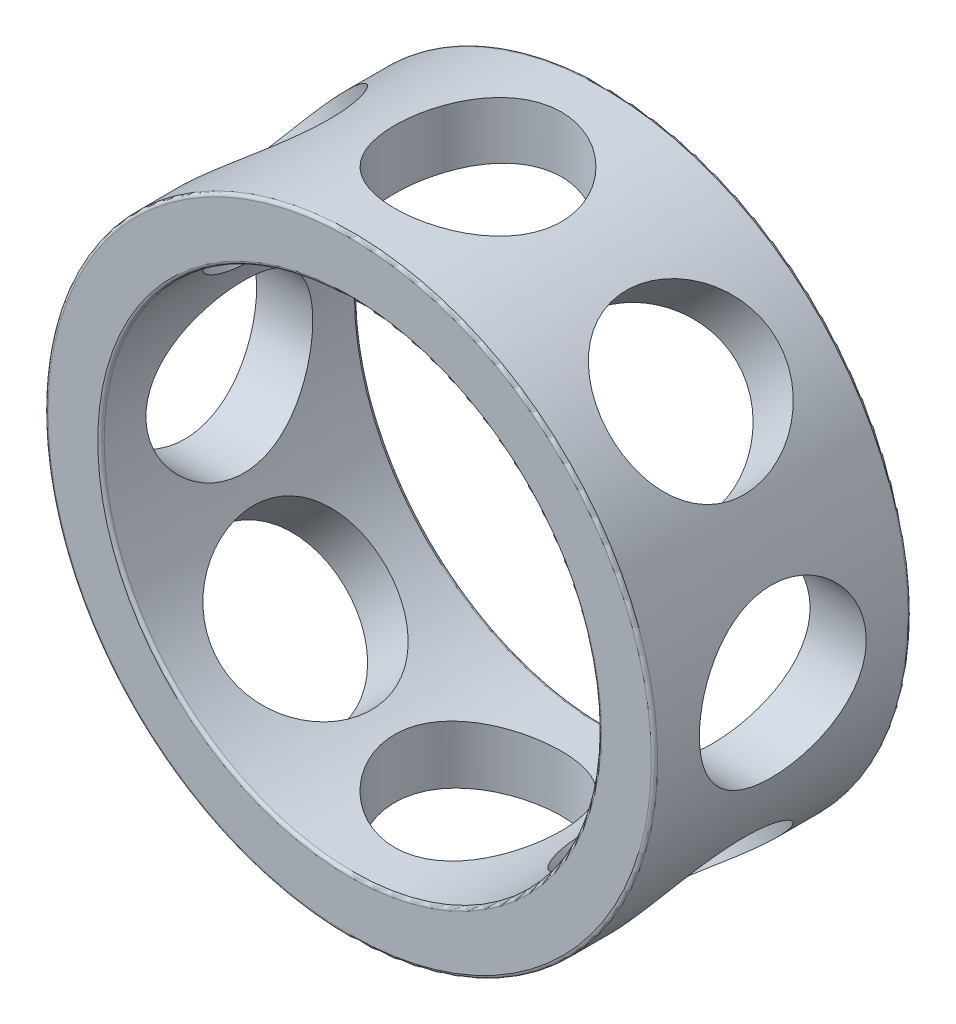
from build123d import *

# Parameters (mm, degrees)
EXTRUDE_1_DEPTH          = 4
EXTRUDE_1_DEPTH_BACK     = 4
SKETCH_1_R               = 9.5
SKETCH_1_R_2             = 7.75
CUT_EXTRUDE_1_REACH      = 16.018
SKETCH_2_R               = 2.6
PATTERN_CIRCULAR_1_COUNT = 8
FILLET_1_R               = 0.1


with BuildPart() as part:
    # Эскиз1 → Бобышка-Вытянуть1 (new, two sides: drawn at the far end of the back side and taken through both)
    with BuildSketch(Plane.XY.offset(-EXTRUDE_1_DEPTH_BACK)):
        Circle(SKETCH_1_R)
        Circle(SKETCH_1_R_2, mode=Mode.SUBTRACT)
    extrude(amount=EXTRUDE_1_DEPTH + EXTRUDE_1_DEPTH_BACK)

    # Эскиз2 → Вырез-Вытянуть1 (cut, up to next)
    with BuildSketch(Plane(origin=(0, 0, 0), x_dir=(1, 0, 0), z_dir=(0, 1, 0)), mode=Mode.PRIVATE) as cut_extrude_1_sk1:
        Circle(SKETCH_2_R)
    cut_extrude_1_tool1 = extrude(cut_extrude_1_sk1.sketch, amount=CUT_EXTRUDE_1_REACH, mode=Mode.PRIVATE) & part.part
    cut_extrude_1 = cut_extrude_1_tool1.solids().sort_by_distance((0, 0, 0))[0]
    add(cut_extrude_1, mode=Mode.SUBTRACT)

    # Круговой массив1: Вырез-Вытянуть1 ×8 about axis
    pattern_circular_1_axis = Axis((0, 0, 4), (0, 0, 1))
    for i in range(1, PATTERN_CIRCULAR_1_COUNT):
        add(cut_extrude_1.rotate(pattern_circular_1_axis, i * 360 / PATTERN_CIRCULAR_1_COUNT), mode=Mode.SUBTRACT)

    # Скругление1
    fillet_1_edges = [part.edges().sort_by_distance(p)[0] for p in [
        (-7.75, 0, -4),
        (-9.5, 0, -4),
        (-7.75, 0, 4),
        (-9.5, 0, 4),
    ]]
    fillet(fillet_1_edges, radius=FILLET_1_R)


solid = part.part
